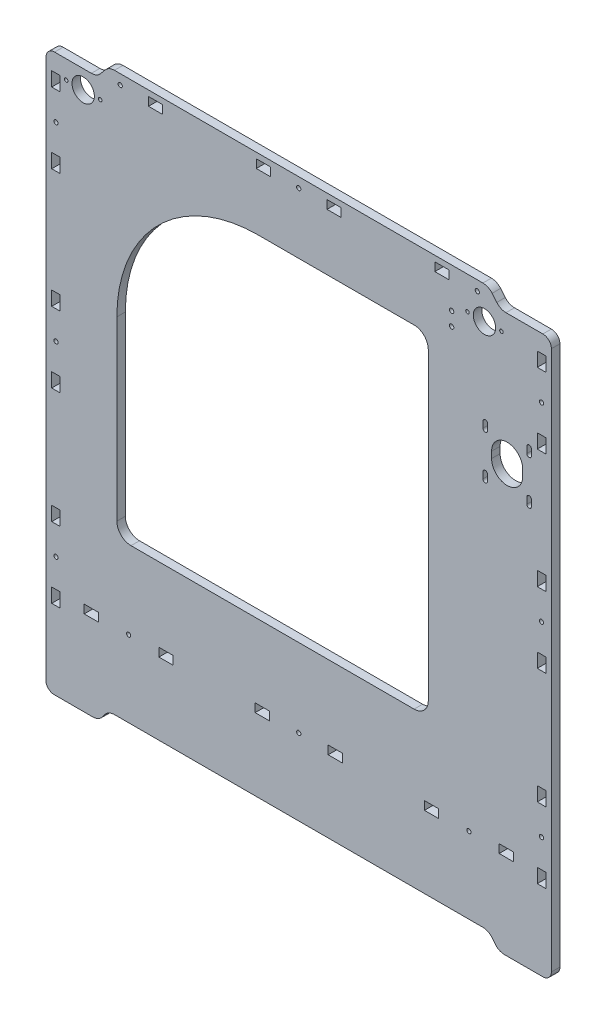
from build123d import *

# Parameters (mm, degrees)
SKETCH_1_R      = 1.55
SKETCH_1_R_2    = 7.9
SKETCH_1_R_3    = 1.500000002
SKETCH_1_R_4    = 1.500000001
SKETCH_1_R_5    = 1.5
SKETCH_1_R_6    = 1.25
SKETCH_1_W      = 6
SKETCH_1_H      = 10
SKETCH_1_W_2    = 10
SKETCH_1_H_2    = 6
EXTRUDE_1_DEPTH = 6


with BuildPart() as part:
    # Эскиз1 → Бобышка-Вытянуть1 (new body)
    with BuildSketch(Plane.XY):
        with BuildLine():
            Line((146.728571026, 193.302051095), (172.76481778, 193.302051095))
            ThreePointArc((172.76481778, 193.302051095), (177.038597027, 191.56796477), (178.819099243, 187.313313634))
            Line((178.819099243, 187.313313634), (178.819099243, -193.997982862))
            ThreePointArc((178.819099243, -193.997982862), (177.042504932, -198.259771734), (172.764817781, -199.997737318))
            Line((172.764817781, -199.997737318), (145.728432875, -199.997737318))
            ThreePointArc((145.728432875, -199.997737318), (142.13617765, -199.201353507), (139.217055109, -196.961432))
            Line((139.217055109, -196.961432), (136.921229056, -193.941778905))
            ThreePointArc((136.921229056, -193.941778905), (134.002106514, -191.701857397), (130.409851289, -190.905473587))
            Line((130.409851289, -190.905473587), (-129.880215727, -190.905473587))
            ThreePointArc((-129.880215727, -190.905473587), (-133.472470952, -191.701857397), (-136.391593494, -193.941778905))
            Line((-136.391593494, -193.941778905), (-138.687419547, -196.961432))
            ThreePointArc((-138.687419547, -196.961432), (-141.606542089, -199.201353507), (-145.198797314, -199.997737318))
            Line((-145.198797314, -199.997737318), (-172.235182219, -199.997737318))
            ThreePointArc((-172.235182219, -199.997737318), (-175.957867453, -198.836968562), (-178.180900757, -195.633237551))
            Line((-178.180900757, -195.633237551), (-178.180900757, 187.302262682))
            ThreePointArc((-178.180900757, 187.302262682), (-176.423541444, 191.54490337), (-172.180900757, 193.302262682))
            Line((-172.180900757, 193.302262682), (-146.198797315, 193.302262682))
            ThreePointArc((-146.198797315, 193.302262682), (-142.60654209, 194.098646493), (-139.687419548, 196.338568))
            Line((-139.687419548, 196.338568), (-136.391593495, 200.265957365))
            ThreePointArc((-136.391593495, 200.265957365), (-133.472470953, 202.505878872), (-129.880215728, 203.302262682))
            Line((-129.880215728, 203.302262682), (130.409851288, 203.302262682))
            ThreePointArc((130.409851288, 203.302262682), (134.002106513, 202.505878872), (136.921229055, 200.265957365))
            Line((136.921229055, 200.265957365), (140.217104458, 196.338462244))
            ThreePointArc((140.217104458, 196.338462244), (143.136253197, 194.098464098), (146.728571026, 193.302051095))
        make_face()
        with Locations((108.319099243, 165.602262682)):
            Circle(SKETCH_1_R, mode=Mode.SUBTRACT)
        with Locations((108.319099243, 175.302262682)):
            Circle(SKETCH_1_R, mode=Mode.SUBTRACT)
        with Locations((131.519099243, 180.302262682)):
            Circle(SKETCH_1_R_2, mode=Mode.SUBTRACT)
        with Locations((-151.980900757, 180.302262682)):
            Circle(SKETCH_1_R_2, mode=Mode.SUBTRACT)
        with Locations((-171.180900757, 150.902262682)):
            Circle(SKETCH_1_R_3, mode=Mode.SUBTRACT)
        with Locations((-171.180900757, 16.742262682)):
            Circle(SKETCH_1_R_4, mode=Mode.SUBTRACT)
        with Locations((171.819099243, 150.902051095)):
            Circle(SKETCH_1_R_4, mode=Mode.SUBTRACT)
        with Locations((126.459099243, 196.302262682)):
            Circle(SKETCH_1_R_5, mode=Mode.SUBTRACT)
        with Locations((-125.820900757, 196.302262682)):
            Circle(SKETCH_1_R_5, mode=Mode.SUBTRACT)
        with Locations((0.319099243, 196.302262682)):
            Circle(SKETCH_1_R_5, mode=Mode.SUBTRACT)
        with Locations((-119.870900757, -136.997737318)):
            Circle(SKETCH_1_R_5, mode=Mode.SUBTRACT)
        with Locations((-171.180900757, -114.967737318)):
            Circle(SKETCH_1_R_5, mode=Mode.SUBTRACT)
        with Locations((0.319099243, -136.997737318)):
            Circle(SKETCH_1_R_5, mode=Mode.SUBTRACT)
        with Locations((120.509099243, -136.997737318)):
            Circle(SKETCH_1_R_5, mode=Mode.SUBTRACT)
        with Locations((171.819099243, -114.967948905)):
            Circle(SKETCH_1_R_5, mode=Mode.SUBTRACT)
        with Locations((171.819099244, 16.742051095)):
            Circle(SKETCH_1_R_5, mode=Mode.SUBTRACT)
        with Locations((-139.980900757, 180.302262682)):
            Circle(SKETCH_1_R_6, mode=Mode.SUBTRACT)
        with Locations((-163.980900757, 180.302262682)):
            Circle(SKETCH_1_R_6, mode=Mode.SUBTRACT)
        with Locations((119.519099243, 180.302262682)):
            Circle(SKETCH_1_R_6, mode=Mode.SUBTRACT)
        with Locations((143.519099243, 180.302262682)):
            Circle(SKETCH_1_R_6, mode=Mode.SUBTRACT)
        with BuildLine():
            Line((133.65547985, 83.46981119), (133.65547985, 87.96981119))
            ThreePointArc((133.65547985, 87.96981119), (132.05547985, 89.56981119), (130.45547985, 87.96981119))
            Line((130.45547985, 87.96981119), (130.45547985, 83.46981119))
            ThreePointArc((130.45547985, 83.46981119), (132.05547985, 81.86981119), (133.65547985, 83.46981119))
        make_face(mode=Mode.SUBTRACT)
        with BuildLine():
            Line((133.65547985, 118.96981119), (133.65547985, 114.46981119))
            ThreePointArc((133.65547985, 114.46981119), (132.05547985, 112.86981119), (130.45547985, 114.46981119))
            Line((130.45547985, 114.46981119), (130.45547985, 118.96981119))
            ThreePointArc((130.45547985, 118.96981119), (132.05547985, 120.56981119), (133.65547985, 118.96981119))
        make_face(mode=Mode.SUBTRACT)
        with BuildLine():
            Line((158.55547985, 98.96981119), (158.55547985, 103.46981119))
            ThreePointArc((158.55547985, 103.46981119), (147.55547985, 114.46981119), (136.55547985, 103.46981119))
            Line((136.55547985, 103.46981119), (136.55547985, 98.96981119))
            ThreePointArc((136.55547985, 98.96981119), (147.55547985, 87.96981119), (158.55547985, 98.96981119))
        make_face(mode=Mode.SUBTRACT)
        with BuildLine():
            Line((161.45547985, 118.96981119), (161.45547985, 114.46981119))
            ThreePointArc((161.45547985, 114.46981119), (163.05547985, 112.86981119), (164.65547985, 114.46981119))
            Line((164.65547985, 114.46981119), (164.65547985, 118.96981119))
            ThreePointArc((164.65547985, 118.96981119), (163.05547985, 120.56981119), (161.45547985, 118.96981119))
        make_face(mode=Mode.SUBTRACT)
        with BuildLine():
            Line((161.45547985, 83.46981119), (161.45547985, 87.96981119))
            ThreePointArc((161.45547985, 87.96981119), (163.05547985, 89.56981119), (164.65547985, 87.96981119))
            Line((164.65547985, 87.96981119), (164.65547985, 83.46981119))
            ThreePointArc((164.65547985, 83.46981119), (163.05547985, 81.86981119), (161.45547985, 83.46981119))
        make_face(mode=Mode.SUBTRACT)
        with Locations((-171.180900756, 41.742262682)):
            Rectangle(SKETCH_1_W, SKETCH_1_H, mode=Mode.SUBTRACT)
        with Locations((94.109099243, -136.997737318)):
            Rectangle(SKETCH_1_W_2, SKETCH_1_H_2, mode=Mode.SUBTRACT)
        with Locations((146.909099243, -136.997737318)):
            Rectangle(SKETCH_1_W_2, SKETCH_1_H_2, mode=Mode.SUBTRACT)
        with Locations((-24.670900757, 196.302262682)):
            Rectangle(SKETCH_1_W_2, SKETCH_1_H_2, mode=Mode.SUBTRACT)
        with Locations((25.309099243, 196.302262682)):
            Rectangle(SKETCH_1_W_2, SKETCH_1_H_2, mode=Mode.SUBTRACT)
        with Locations((-146.270900757, -136.997737318)):
            Rectangle(SKETCH_1_W_2, SKETCH_1_H_2, mode=Mode.SUBTRACT)
        with Locations((-93.470900757, -136.997737318)):
            Rectangle(SKETCH_1_W_2, SKETCH_1_H_2, mode=Mode.SUBTRACT)
        with Locations((-25.470900757, -136.997737318)):
            Rectangle(SKETCH_1_W_2, SKETCH_1_H_2, mode=Mode.SUBTRACT)
        with Locations((26.109099243, -136.997737318)):
            Rectangle(SKETCH_1_W_2, SKETCH_1_H_2, mode=Mode.SUBTRACT)
        with Locations((-171.180900757, -8.257737318)):
            Rectangle(SKETCH_1_W, SKETCH_1_H, mode=Mode.SUBTRACT)
        with Locations((-171.180900757, 175.902262682)):
            Rectangle(SKETCH_1_W, SKETCH_1_H, mode=Mode.SUBTRACT)
        with Locations((-171.180900757, 125.902262682)):
            Rectangle(SKETCH_1_W, SKETCH_1_H, mode=Mode.SUBTRACT)
        with Locations((-171.180900756, -89.987737318)):
            Rectangle(SKETCH_1_W, SKETCH_1_H, mode=Mode.SUBTRACT)
        with Locations((-171.180900757, -139.977737318)):
            Rectangle(SKETCH_1_W, SKETCH_1_H, mode=Mode.SUBTRACT)
        with Locations((171.819099243, 41.742051095)):
            Rectangle(SKETCH_1_W, SKETCH_1_H, mode=Mode.SUBTRACT)
        with Locations((171.819099243, -8.257948905)):
            Rectangle(SKETCH_1_W, SKETCH_1_H, mode=Mode.SUBTRACT)
        with Locations((171.819099244, -89.987948905)):
            Rectangle(SKETCH_1_W, SKETCH_1_H, mode=Mode.SUBTRACT)
        with Locations((171.819099243, -139.977948905)):
            Rectangle(SKETCH_1_W, SKETCH_1_H, mode=Mode.SUBTRACT)
        Polygon((168.819099243, 170.902051095), (168.819099243, 180.902051095), (174.819099243, 180.902051095), (174.819099243, 170.978103712), (175.145177162, 170.902051095), align=None, mode=Mode.SUBTRACT)
        with Locations((171.819099243, 125.902051095)):
            Rectangle(SKETCH_1_W, SKETCH_1_H, mode=Mode.SUBTRACT)
        with Locations((-100.820900757, 196.302262682)):
            Rectangle(SKETCH_1_W_2, SKETCH_1_H_2, mode=Mode.SUBTRACT)
        with Locations((101.459099243, 196.302262682)):
            Rectangle(SKETCH_1_W_2, SKETCH_1_H_2, mode=Mode.SUBTRACT)
        with BuildLine():
            Line((-128.180900757, -71.697737318), (-128.180900757, 53.302262682))
            ThreePointArc((-128.180900757, 53.302262682), (-98.891578875, 124.012940801), (-28.180900757, 153.302262682))
            Line((-28.180900757, 153.302262682), (81.819099243, 153.302262682))
            ThreePointArc((81.819099243, 153.302262682), (88.890167055, 150.373330494), (91.819099243, 143.302262682))
            Line((91.819099243, 143.302262682), (91.819099243, -71.697737318))
            ThreePointArc((91.819099243, -71.697737318), (88.890167055, -78.768805129), (81.819099243, -81.697737318))
            Line((81.819099243, -81.697737318), (-118.180900757, -81.697737318))
            ThreePointArc((-118.180900757, -81.697737318), (-125.251968568, -78.768805129), (-128.180900757, -71.697737318))
        make_face(mode=Mode.SUBTRACT)
    extrude(amount=EXTRUDE_1_DEPTH)


solid = part.part
